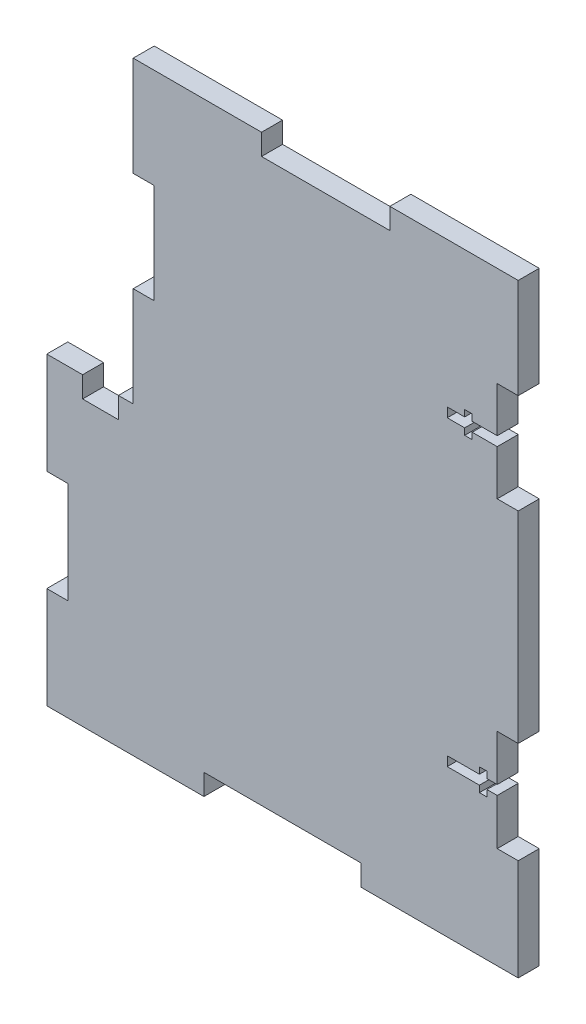
from build123d import *

# Parameters (mm, degrees)
SKETCH1_W           = 129.9464
SKETCH1_H           = 83.9724
BOSS_EXTRUDE1_DEPTH = 5.7912
SKETCH2_W           = 9.872133334
SKETCH2_H           = 5.7912
CUT_EXTRUDE1_DEPTH  = 6.7912
SKETCH3_W           = 5.7912
SKETCH3_H           = 27.9908
CUT_EXTRUDE2_DEPTH  = 6.7912
SKETCH4_W           = 13.7668
SKETCH4_H           = 2.6035
CUT_EXTRUDE3_DEPTH  = 6.7912
SKETCH6_W           = 2.0828
SKETCH6_H           = 6.1722
CUT_EXTRUDE5_DEPTH  = 6.7912
SKETCH7_W           = 106.1212
SKETCH7_H           = 82.55
BOSS_EXTRUDE2_DEPTH = 5.7912
SKETCH8_W           = 43.315466666
SKETCH8_H           = 5.7912
CUT_EXTRUDE6_DEPTH  = 6.7912
SKETCH12_W          = 5.7912
SKETCH12_H          = 27.516666666
CUT_EXTRUDE9_DEPTH  = 6.7912
SKETCH13_W          = 13.7668
SKETCH13_H          = 2.6035
CUT_EXTRUDE10_DEPTH = 6.7912
SKETCH14_W          = 2.0828
SKETCH14_H          = 6.1722
CUT_EXTRUDE11_DEPTH = 6.7912
SKETCH15_W          = 35.373733334
SKETCH15_H          = 5.7912
CUT_EXTRUDE12_DEPTH = 6.7912


with BuildPart() as part:
    # Sketch1 → Boss-Extrude1 (new body)
    with BuildSketch(Plane.XY):
        Rectangle(SKETCH1_W, SKETCH1_H)
    extrude(amount=BOSS_EXTRUDE1_DEPTH)

    # Sketch2 → Cut-Extrude1 (cut, through all)
    with BuildSketch(Plane.XY.offset(5.7912)):
        with Locations((-50.165, 39.0906)):
            Rectangle(SKETCH2_W, SKETCH2_H)
    extrude(amount=-CUT_EXTRUDE1_DEPTH, mode=Mode.SUBTRACT)

    # Sketch3 → Cut-Extrude2 (cut, through all)
    with BuildSketch(Plane.XY.offset(5.7912)):
        with Locations((-62.0776, 0)):
            Rectangle(SKETCH3_W, SKETCH3_H)
        with Locations((62.0776, 0)):
            Rectangle(SKETCH3_W, SKETCH3_H)
    extrude(amount=-CUT_EXTRUDE2_DEPTH, mode=Mode.SUBTRACT)

    # Sketch4 → Cut-Extrude3 (cut, through all)
    with BuildSketch(Plane.XY.offset(5.7912)):
        with Locations((52.2986, 0)):
            Rectangle(SKETCH4_W, SKETCH4_H)
    extrude(amount=-CUT_EXTRUDE3_DEPTH, mode=Mode.SUBTRACT)

    # Sketch6 → Cut-Extrude5 (cut, through all)
    with BuildSketch(Plane.XY.offset(5.7912)):
        with Locations((55.3212, 0)):
            Rectangle(SKETCH6_W, SKETCH6_H)
    extrude(amount=-CUT_EXTRUDE5_DEPTH, mode=Mode.SUBTRACT)

    # Sketch7 → Boss-Extrude2 (add)
    with BuildSketch(Plane.XY.offset(5.7912)):
        with Locations((11.9126, 83.2612)):
            Rectangle(SKETCH7_W, SKETCH7_H)
    extrude(amount=-BOSS_EXTRUDE2_DEPTH)

    # Sketch8 → Cut-Extrude6 (cut, through all)
    with BuildSketch(Plane.XY.offset(5.7912)):
        with Locations((0, -39.0906)):
            Rectangle(SKETCH8_W, SKETCH8_H)
    extrude(amount=-CUT_EXTRUDE6_DEPTH, mode=Mode.SUBTRACT)

    # Sketch12 → Cut-Extrude9 (cut, through all)
    with BuildSketch(Plane.XY.offset(5.7912)):
        with Locations((62.0776, 83.2612)):
            Rectangle(SKETCH12_W, SKETCH12_H)
        with Locations((-38.2524, 83.2612)):
            Rectangle(SKETCH12_W, SKETCH12_H)
    extrude(amount=-CUT_EXTRUDE9_DEPTH, mode=Mode.SUBTRACT)

    # Sketch13 → Cut-Extrude10 (cut, through all)
    with BuildSketch(Plane.XY.offset(5.7912)):
        with Locations((52.2986, 83.2612)):
            Rectangle(SKETCH13_W, SKETCH13_H)
    extrude(amount=-CUT_EXTRUDE10_DEPTH, mode=Mode.SUBTRACT)

    # Sketch14 → Cut-Extrude11 (cut, through all)
    with BuildSketch(Plane.XY.offset(5.7912)):
        with Locations((51.2572, 83.2612)):
            Rectangle(SKETCH14_W, SKETCH14_H)
    extrude(amount=-CUT_EXTRUDE11_DEPTH, mode=Mode.SUBTRACT)

    # Sketch15 → Cut-Extrude12 (cut, through all)
    with BuildSketch(Plane.XY.offset(5.7912)):
        with Locations((11.9126, 121.6406)):
            Rectangle(SKETCH15_W, SKETCH15_H)
    extrude(amount=-CUT_EXTRUDE12_DEPTH, mode=Mode.SUBTRACT)


solid = part.part
